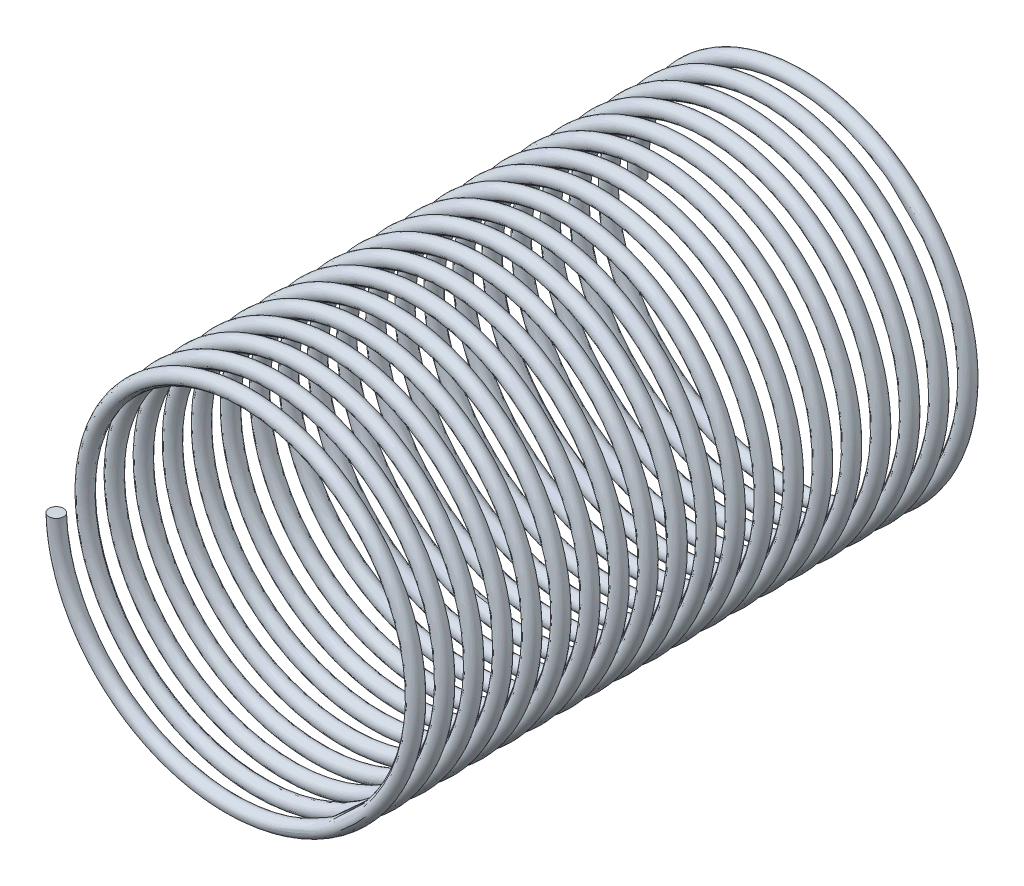
from build123d import *

# Parameters (mm, degrees)
SWEEP1_PITCH       = 10
SWEEP1_HEIGHT      = 200
SWEEP1_RADIUS      = 60
SWEEP1_START_ANGLE = -180
SKETCH4_R          = 2.5


with BuildPart() as part:
    # Sweep1: sweep along a helix
    with BuildLine() as sweep1_path:
        add(Helix(SWEEP1_PITCH, SWEEP1_HEIGHT, SWEEP1_RADIUS, center=(0, 0, 0), direction=(0, 0, 1), lefthand=True, mode=Mode.PRIVATE).rotate(Axis((0, 0, 0), (0, 0, 1)), SWEEP1_START_ANGLE))
    # Sketch4 → Sweep1 (sweep)
    with BuildSketch(Plane(origin=(0, 0, 0), x_dir=(1, 0, 0), z_dir=(0, 1, 0))):
        with Locations((-59.292872329, -0.971909338)):
            Circle(SKETCH4_R)
    sweep(path=sweep1_path.line, is_frenet=True)


solid = part.part
